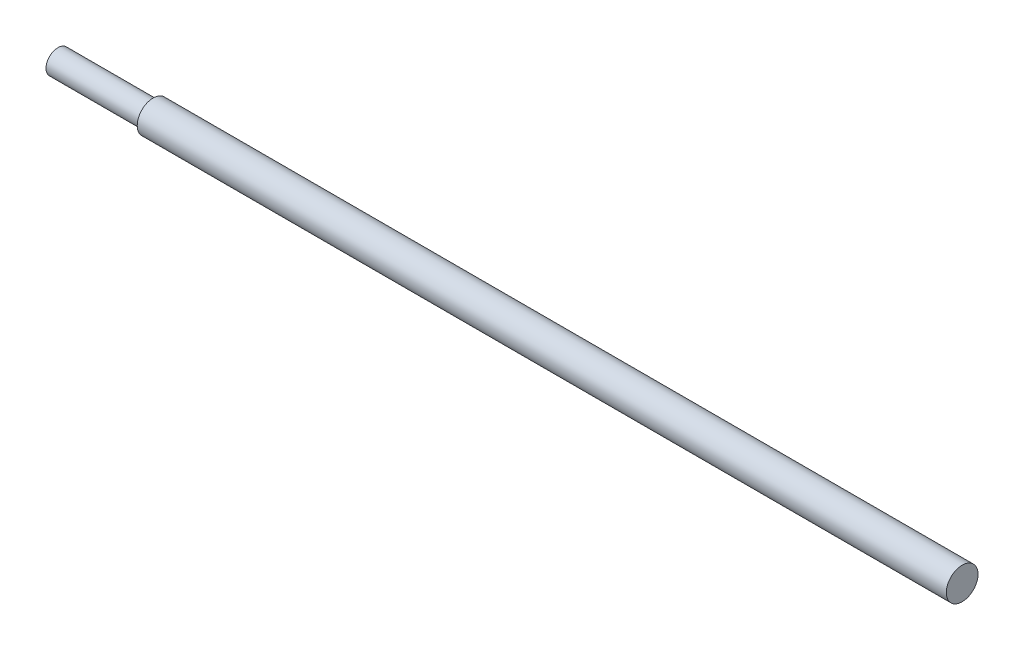
from build123d import *

# Parameters (mm, degrees)
SKETCH3_W               = 25.4
SKETCH3_H               = 3.175
CUT_EXTRUDE1_DEPTH      = 725.12277274
CUT_EXTRUDE1_DEPTH_BACK = 725.12277274


with BuildPart() as part:
    # Sketch2 → Revolve1 (revolve)
    with BuildSketch(Plane(origin=(0, 0, 0), x_dir=(1, 0, 0), z_dir=(0, 1, 0)), mode=Mode.PRIVATE) as revolve1_sk:
        Polygon((-723.9, 9.525), (-723.9, 0), (0, 0), (0, 12.7), (-647.7, 12.7), (-647.7, 9.525), align=None)
    revolve(revolve1_sk.sketch.rotate(Axis((-723.9, 0, 0), (1, 0, 0)), 180), axis=Axis((-723.9, 0, 0), (1, 0, 0)))

    # Sketch3 → Cut-Extrude1 (cut, two sides)
    with BuildSketch(Plane(origin=(0, 0, 0), x_dir=(1, 0, 0), z_dir=(0, 1, 0))) as cut_extrude1_sk:
        with Locations((-411.48, 11.1125)):
            Rectangle(SKETCH3_W, SKETCH3_H)
    extrude(amount=CUT_EXTRUDE1_DEPTH, mode=Mode.SUBTRACT)
    extrude(cut_extrude1_sk.sketch, amount=-CUT_EXTRUDE1_DEPTH_BACK, mode=Mode.SUBTRACT)


solid = part.part
